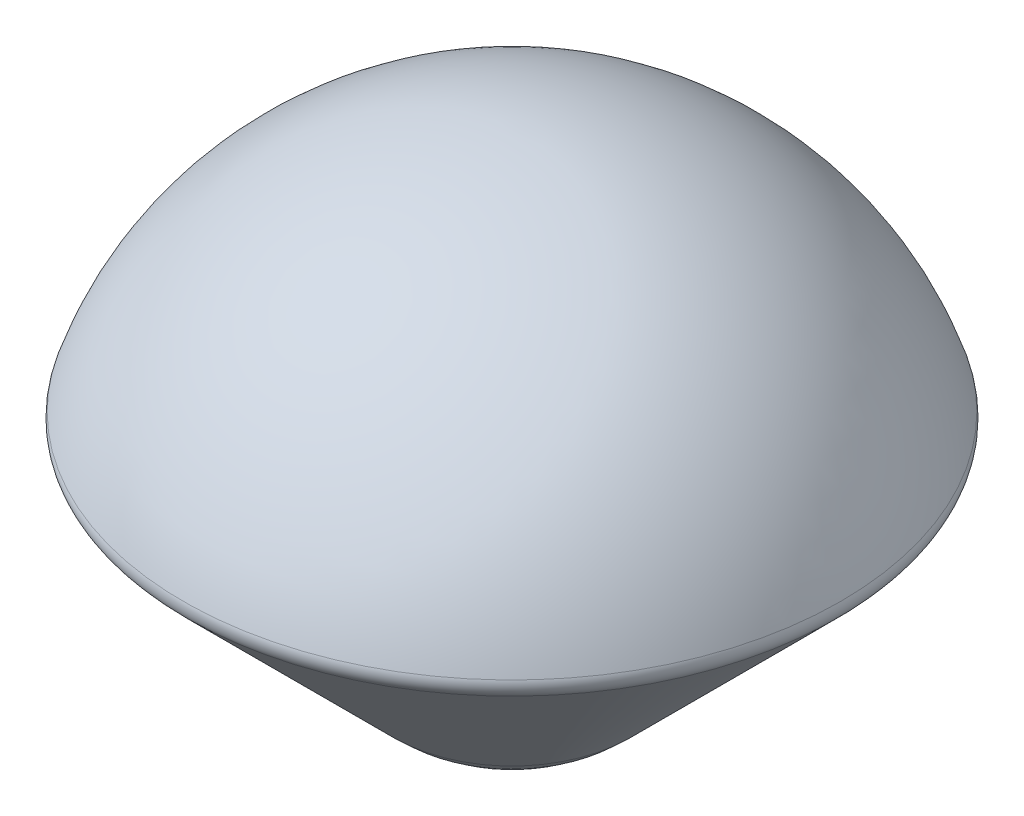
from build123d import *

# Parameters (mm, degrees)
FILLET1_R = 2.5


with BuildPart() as part:
    # Sketch3 → Revolve3 (revolve)
    with BuildSketch(Plane.XY):
        with BuildLine():
            Line((0, 39.546124031), (0, -37.553875969))
            ThreePointArc((0, -37.553875969), (9.630529218, -35.624482961), (17.774572377, -30.134108527))
            Line((17.774572377, -30.134108527), (49.999445132, 2.090764227))
            ThreePointArc((49.999445132, 2.090764227), (31.236391003, 29.143820336), (0, 39.546124031))
        make_face()
    revolve(axis=Axis((0, 39.546124031, 0), (0, -1, 0)))

    # Fillet1
    fillet1_edges = [part.edges().sort_by_distance(p)[0] for p in [
        (-49.999445132, 2.090764227, 0),
    ]]
    fillet(fillet1_edges, radius=FILLET1_R)


solid = part.part
